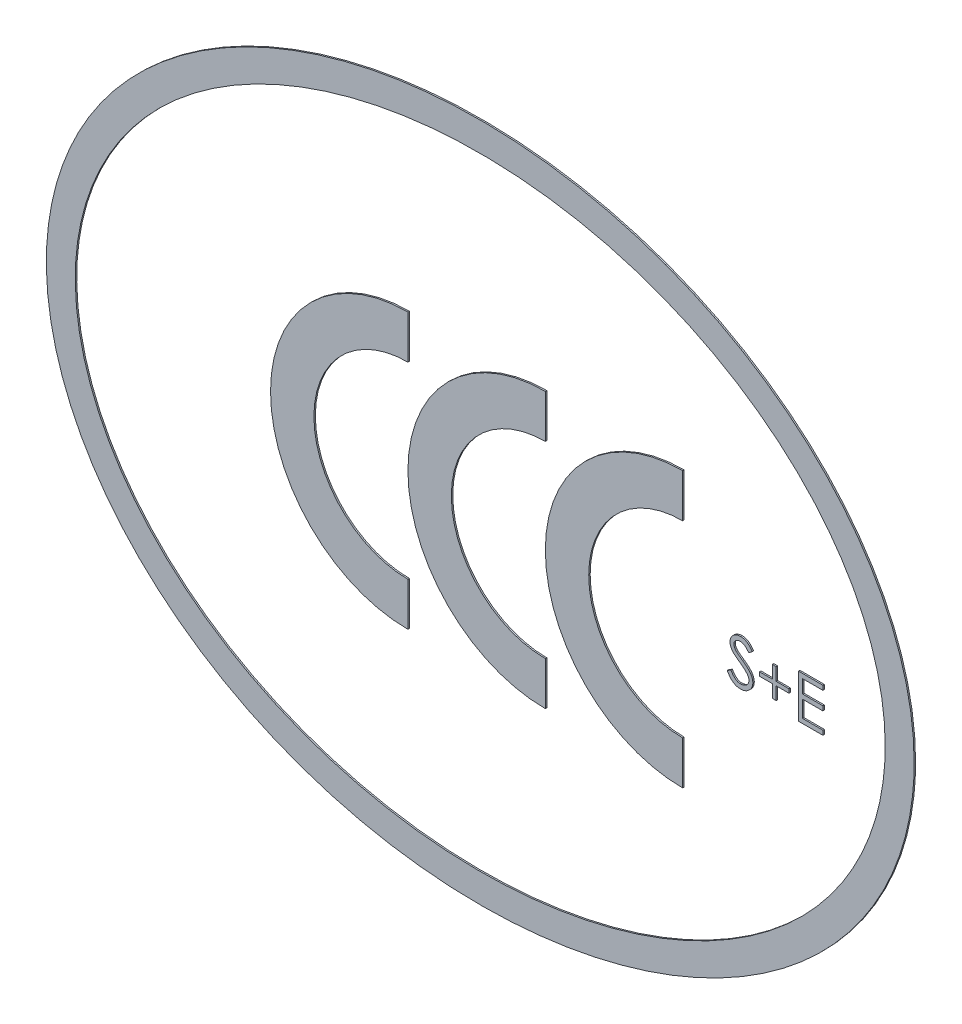
from build123d import *

# Parameters (mm, degrees)
SKIZZE1_RX                        = 30
SKIZZE1_RY                        = 23.5
SKIZZE1_RX_2                      = 28
SKIZZE1_RY_2                      = 21.5
AUFSATZ_LINEAR_AUSTRAGEN1_DEPTH   = 0.1
AUFSATZ_LINEAR_AUSTRAGEN1_2_DEPTH = 0.1
AUFSATZ_LINEAR_AUSTRAGEN1_3_DEPTH = 0.1
AUFSATZ_LINEAR_AUSTRAGEN1_4_DEPTH = 0.1
AUFSATZ_LINEAR_AUSTRAGEN2_DEPTH   = 0.1
AUFSATZ_LINEAR_AUSTRAGEN2_2_DEPTH = 0.1
AUFSATZ_LINEAR_AUSTRAGEN2_3_DEPTH = 0.1


with BuildPart() as part:
    # Skizze1 → Aufsatz-Linear austragen1 (new body)
    with BuildSketch(Plane.XY):
        with Locations((0, 0)):
            Ellipse(SKIZZE1_RX, SKIZZE1_RY)
        with Locations((0, 0)):
            Ellipse(SKIZZE1_RX_2, SKIZZE1_RY_2, mode=Mode.SUBTRACT)
    extrude(amount=AUFSATZ_LINEAR_AUSTRAGEN1_DEPTH)


with BuildPart() as body_2:
    # Skizze1 → Aufsatz-Linear austragen1 2 (new body)
    with BuildSketch(Plane.XY):
        with BuildLine():
            ThreePointArc((-5, 6.5), (-11.5, 0), (-5, -6.5))
            Line((-5, -6.5), (-5, -9.5))
            ThreePointArc((-5, -9.5), (-14.5, 0), (-5, 9.5))
            Line((-5, 9.5), (-5, 6.5))
        make_face()
    extrude(amount=AUFSATZ_LINEAR_AUSTRAGEN1_2_DEPTH)


with BuildPart() as body_3:
    # Skizze1 → Aufsatz-Linear austragen1 3 (new body)
    with BuildSketch(Plane.XY):
        with BuildLine():
            ThreePointArc((4.5, 6.5), (-2, 0), (4.5, -6.5))
            Line((4.5, -6.5), (4.5, -9.5))
            ThreePointArc((4.5, -9.5), (-5, 0), (4.5, 9.5))
            Line((4.5, 9.5), (4.5, 6.5))
        make_face()
    extrude(amount=AUFSATZ_LINEAR_AUSTRAGEN1_3_DEPTH)


with BuildPart() as body_4:
    # Skizze1 → Aufsatz-Linear austragen1 4 (new body)
    with BuildSketch(Plane.XY):
        with BuildLine():
            ThreePointArc((14, 6.5), (7.5, 0), (14, -6.5))
            Line((14, -6.5), (14, -9.5))
            ThreePointArc((14, -9.5), (4.5, 0), (14, 9.5))
            Line((14, 9.5), (14, 6.5))
        make_face()
    extrude(amount=AUFSATZ_LINEAR_AUSTRAGEN1_4_DEPTH)


with BuildPart() as body_5:
    # Skizze4 → Aufsatz-Linear austragen2 (new body)
    with BuildSketch(Plane.XY):
        with BuildLine():
            Line((17.076923077, -0.921274038), (17.330528846, -0.769230769))
            add(Edge.make_bspline(
                [(17.330528846, -0.769230769), (17.354115907, -0.808714528), (17.399307804, -0.884363885), (17.474694684, -0.986585063), (17.552808607, -1.073466912), (17.634228036, -1.144504004), (17.718455992, -1.200431621), (17.806042324, -1.240033534), (17.896691876, -1.264732941), (17.958383723, -1.267733015), (17.989182692, -1.269230769)],
                knots=[0, 0, 0, 0, 1.272034388, 2.437168799, 3.508375237, 4.49857839, 5.41946034, 6.295179144, 7.148887113, 8, 8, 8, 8], degree=3))
            add(Edge.make_bspline(
                [(17.989182692, -1.269230769), (18.015485716, -1.268498193), (18.067631521, -1.267045858), (18.144399158, -1.253090885), (18.218954988, -1.231651917), (18.289762392, -1.200948262), (18.355844347, -1.163800988), (18.413792943, -1.118932836), (18.463889612, -1.068698946), (18.504868853, -1.01265667), (18.536308883, -0.952384829), (18.560473513, -0.890519727), (18.573883576, -0.826089526), (18.575903651, -0.782709129), (18.576923077, -0.760817308)],
                knots=[0, 0, 0, 0, 1.095163259, 2.171163733, 3.241058638, 4.321873601, 5.38011039, 6.391990106, 7.366004449, 8.327778327, 9.272591725, 10.192022065, 11.087607919, 12, 12, 12, 12], degree=3))
            add(Edge.make_bspline(
                [(18.576923077, -0.760817308), (18.575659382, -0.735839437), (18.573090475, -0.685063074), (18.551377778, -0.610149086), (18.51722128, -0.536012598), (18.485710443, -0.49015437), (18.469350962, -0.466346154)],
                knots=[0, 0, 0, 0, 0.938893495, 1.908633276, 2.914225137, 4, 4, 4, 4], degree=3))
            add(Edge.make_bspline(
                [(18.469350962, -0.466346154), (18.455919007, -0.449163162), (18.427720297, -0.413089621), (18.379242429, -0.359393704), (18.322357188, -0.304006488), (18.259011284, -0.244813011), (18.186897208, -0.184566328), (18.108273624, -0.120393518), (18.021133174, -0.054735024), (17.960019319, -0.010701396), (17.928485577, 0.012019231)],
                knots=[0, 0, 0, 0, 0.722233717, 1.516239348, 2.393582979, 3.351407094, 4.387010283, 5.505090956, 6.712668013, 8, 8, 8, 8], degree=3))
            add(Edge.make_bspline(
                [(17.928485577, 0.012019231), (17.896922152, 0.034500877), (17.836575286, 0.077484074), (17.752182215, 0.141276317), (17.676715533, 0.199599634), (17.610510662, 0.253003073), (17.553596721, 0.301493877), (17.505525226, 0.344606396), (17.467520749, 0.383506591), (17.446387394, 0.408742027), (17.436899038, 0.420072115)],
                knots=[0, 0, 0, 0, 1.452282411, 2.77665338, 3.964542531, 5.026858415, 5.96415736, 6.766646006, 7.446254459, 8, 8, 8, 8], degree=3))
            add(Edge.make_bspline(
                [(17.436899038, 0.420072115), (17.423636857, 0.437730147), (17.397554997, 0.472457036), (17.363126992, 0.526735485), (17.333864853, 0.582298284), (17.310925711, 0.63929474), (17.291608952, 0.696924679), (17.27861644, 0.755940032), (17.270480957, 0.816075991), (17.269647825, 0.856544706), (17.269230769, 0.876802885)],
                knots=[0, 0, 0, 0, 1.068054152, 2.10047183, 3.106115577, 4.101338837, 5.06977816, 6.043150881, 7.020423561, 8, 8, 8, 8], degree=3))
            add(Edge.make_bspline(
                [(17.269230769, 0.876802885), (17.27034952, 0.908542691), (17.272563108, 0.971343889), (17.291283552, 1.063084601), (17.320831746, 1.150672958), (17.362227365, 1.233241816), (17.41559081, 1.308641228), (17.477344502, 1.377738503), (17.550897205, 1.435825859), (17.631599453, 1.486579052), (17.719933486, 1.52630413), (17.812497118, 1.556270685), (17.909437465, 1.573250049), (17.975097295, 1.575686704), (18.008413462, 1.576923077)],
                knots=[0, 0, 0, 0, 1.005424448, 1.989358655, 2.955360095, 3.929531133, 4.905563448, 5.876582895, 6.856512386, 7.866279853, 8.892233794, 9.918561126, 10.94386622, 12, 12, 12, 12], degree=3))
            add(Edge.make_bspline(
                [(18.008413462, 1.576923077), (18.043765548, 1.575703747), (18.114069563, 1.573278889), (18.217483177, 1.552195291), (18.317049505, 1.517309001), (18.397143732, 1.477718722), (18.459828956, 1.438177509), (18.507634156, 1.402160517), (18.556077685, 1.360696138), (18.605550303, 1.313673927), (18.655213726, 1.260662426), (18.705805256, 1.202024693), (18.757443201, 1.138119073), (18.790662509, 1.092498073), (18.807692308, 1.069110577)],
                knots=[0, 0, 0, 0, 1.286793592, 2.559021753, 3.825965368, 5.121522368, 5.803751409, 6.523245864, 7.299691795, 8.125521123, 9.008227632, 9.944561021, 10.946284179, 12, 12, 12, 12], degree=3))
            Line((18.807692308, 1.069110577), (18.564302885, 0.884615385))
            add(Edge.make_bspline(
                [(18.564302885, 0.884615385), (18.549606371, 0.903548548), (18.521304322, 0.940009393), (18.478336191, 0.991070521), (18.437837349, 1.037713218), (18.397937007, 1.078226185), (18.360742466, 1.114828013), (18.324642144, 1.146164948), (18.290155557, 1.17254403), (18.246683919, 1.200695652), (18.192068732, 1.228601227), (18.123510558, 1.252214722), (18.051865179, 1.266404775), (18.003068353, 1.268280965), (17.978365385, 1.269230769)],
                knots=[0, 0, 0, 0, 1.181633172, 2.275549214, 3.290209073, 4.226197932, 5.078386478, 5.862611352, 6.581680152, 7.217281963, 8.414376989, 9.595101626, 10.782541182, 12, 12, 12, 12], degree=3))
            add(Edge.make_bspline(
                [(17.978365385, 1.269230769), (17.94737408, 1.268192169), (17.887610268, 1.266189327), (17.802761494, 1.244315054), (17.726395272, 1.209873459), (17.660778788, 1.161603478), (17.606147093, 1.104414056), (17.566628129, 1.038603609), (17.542842273, 0.965932978), (17.539939748, 0.91524013), (17.538461538, 0.889423077)],
                knots=[0, 0, 0, 0, 1.14458467, 2.207223713, 3.21896685, 4.227309161, 5.202851033, 6.127160689, 7.046193047, 8, 8, 8, 8], degree=3))
            add(Edge.make_bspline(
                [(17.538461538, 0.889423077), (17.538798504, 0.873350381), (17.539472987, 0.841178707), (17.548879956, 0.793648917), (17.560965095, 0.746239197), (17.580115922, 0.699162698), (17.606554754, 0.651596104), (17.641273476, 0.602720329), (17.684999172, 0.552104579), (17.718493754, 0.519183973), (17.736177885, 0.501802885)],
                knots=[0, 0, 0, 0, 0.858281714, 1.717966888, 2.583508476, 3.4729293, 4.427298488, 5.488583878, 6.674047936, 8, 8, 8, 8], degree=3))
            add(Edge.make_bspline(
                [(17.736177885, 0.501802885), (17.742744775, 0.495942577), (17.758346204, 0.482019827), (17.786868426, 0.459226443), (17.824533682, 0.431109781), (17.870358426, 0.396320653), (17.925187593, 0.355965114), (17.989027213, 0.310559161), (18.061165669, 0.258628767), (18.112355883, 0.222322304), (18.139423077, 0.203125)],
                knots=[0, 0, 0, 0, 0.420754252, 0.999615792, 1.744751191, 2.668019286, 3.750313428, 4.999500688, 6.413464383, 8, 8, 8, 8], degree=3))
            add(Edge.make_bspline(
                [(18.139423077, 0.203125), (18.171982431, 0.179432406), (18.235029108, 0.133554982), (18.324735605, 0.064627256), (18.406073155, -0.002785117), (18.479327329, -0.068251637), (18.545221822, -0.131275717), (18.603025583, -0.192615586), (18.653327595, -0.251831791), (18.707481211, -0.327751142), (18.762816484, -0.420992071), (18.810337776, -0.535230561), (18.840302074, -0.649913122), (18.844220516, -0.726993267), (18.846153846, -0.765024038)],
                knots=[0, 0, 0, 0, 1.163667725, 2.253281268, 3.268753668, 4.215851969, 5.092017293, 5.902905408, 6.650798638, 7.335211899, 8.59617414, 9.77448103, 10.901945474, 12, 12, 12, 12], degree=3))
            add(Edge.make_bspline(
                [(18.846153846, -0.765024038), (18.845590585, -0.79191978), (18.844475001, -0.845188966), (18.83165136, -0.923407603), (18.812863076, -0.99937692), (18.784545447, -1.072157874), (18.74998274, -1.143081956), (18.706125956, -1.210288728), (18.655290797, -1.275265641), (18.596976142, -1.336280062), (18.533165368, -1.392291087), (18.465722201, -1.442115997), (18.394536253, -1.483660274), (18.319993696, -1.517560996), (18.242077407, -1.544075439), (18.160813593, -1.56328647), (18.076068297, -1.575077079), (18.018467885, -1.576300875), (17.989182692, -1.576923077)],
                knots=[0, 0, 0, 0, 0.983748083, 1.948392443, 2.894712957, 3.844097841, 4.80183111, 5.778335162, 6.776009319, 7.81870978, 8.863265674, 9.881300176, 10.883814829, 11.87499822, 12.874611388, 13.892143829, 14.928324115, 16, 16, 16, 16], degree=3))
            add(Edge.make_bspline(
                [(17.989182692, -1.576923077), (17.966523827, -1.576484921), (17.921491461, -1.575614128), (17.854883334, -1.567915888), (17.789620829, -1.557024085), (17.726522873, -1.539732025), (17.66477652, -1.518751759), (17.604650319, -1.492918902), (17.54611513, -1.461961301), (17.488842916, -1.426565565), (17.432979338, -1.385373213), (17.379048365, -1.33739593), (17.325280492, -1.283956926), (17.273262724, -1.223605015), (17.221942886, -1.157315229), (17.17233282, -1.084467358), (17.123405634, -1.005458197), (17.092706661, -0.949859553), (17.076923077, -0.921274038)],
                knots=[0, 0, 0, 0, 0.915332311, 1.819136955, 2.706846663, 3.586547465, 4.459518054, 5.340707479, 6.227863349, 7.133153174, 8.059268498, 9.028702269, 10.047606654, 11.120612155, 12.245963614, 13.433783089, 14.680604001, 16, 16, 16, 16], degree=3))
        make_face()
    extrude(amount=AUFSATZ_LINEAR_AUSTRAGEN2_DEPTH)


with BuildPart() as body_6:
    # Skizze4 → Aufsatz-Linear austragen2 2 (new body)
    with BuildSketch(Plane.XY):
        Polygon((20.192307692, 0.115384615), (20.192307692, 1), (20.461538462, 1), (20.461538462, 0.115384615), (21.346153846, 0.115384615), (21.346153846, -0.153846154), (20.461538462, -0.153846154), (20.461538462, -1.038461538), (20.192307692, -1.038461538), (20.192307692, -0.153846154), (19.307692308, -0.153846154), (19.307692308, 0.115384615), align=None)
    extrude(amount=AUFSATZ_LINEAR_AUSTRAGEN2_2_DEPTH)


with BuildPart() as body_7:
    # Skizze4 → Aufsatz-Linear austragen2 3 (new body)
    with BuildSketch(Plane.XY):
        Polygon((22, 1.5), (23.692307692, 1.5), (23.692307692, 1.192307692), (22.269230769, 1.192307692), (22.269230769, 0.269230769), (23.692307692, 0.269230769), (23.692307692, -0.038461538), (22.269230769, -0.038461538), (22.269230769, -1.192307692), (23.692307692, -1.192307692), (23.692307692, -1.5), (22, -1.5), align=None)
    extrude(amount=AUFSATZ_LINEAR_AUSTRAGEN2_3_DEPTH)


solid = Compound([part.part, body_2.part, body_3.part, body_4.part, body_5.part, body_6.part, body_7.part])
